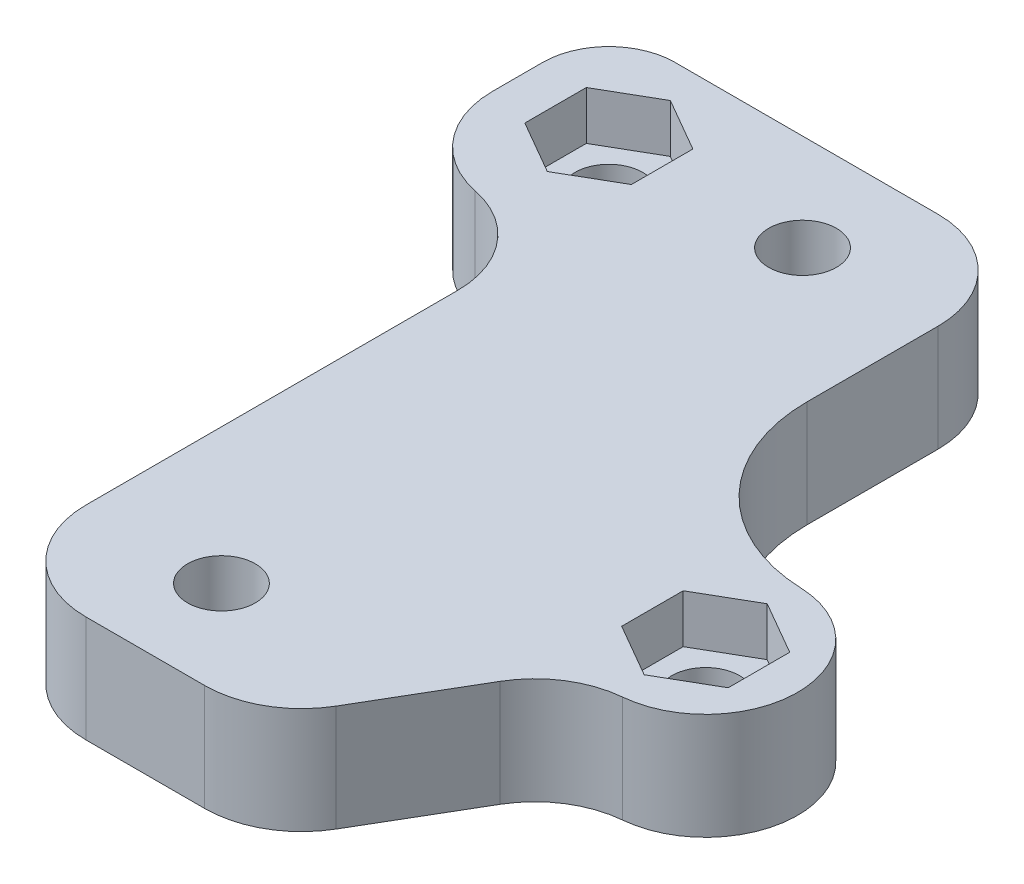
from build123d import *

# Parameters (mm, degrees)
SKETCH2_W           = 35
SKETCH2_H           = 40
SKETCH2_R           = 1.75
BOSS_EXTRUDE2_DEPTH = 5.5
CUT_EXTRUDE1_REACH  = 10.5
CUT_EXTRUDE1_START  = -3
CUT_EXTRUDE2_START  = -3
CUT_EXTRUDE2_DEPTH  = 10
CUT_EXTRUDE3_DEPTH  = 6.5
FILLET3_R           = 5
FILLET4_R           = 8.5


with BuildPart() as part:
    # Sketch2 → Boss-Extrude2 (new body)
    with BuildSketch(Plane(origin=(0, 0, 0), x_dir=(1, 0, 0), z_dir=(0, 1, 0))):
        with Locations((17.5, 20)):
            Rectangle(SKETCH2_W, SKETCH2_H)
        with Locations((5, 35)):
            Circle(SKETCH2_R, mode=Mode.SUBTRACT)
        with Locations((30, 15)):
            Circle(SKETCH2_R, mode=Mode.SUBTRACT)
        with Locations((15, 35)):
            Circle(SKETCH2_R, mode=Mode.SUBTRACT)
        with Locations((15, 5)):
            Circle(SKETCH2_R, mode=Mode.SUBTRACT)
    extrude(amount=BOSS_EXTRUDE2_DEPTH)

    # Sketch3 → Cut-Extrude1 (cut, up to next)
    with BuildSketch(Plane.XZ.offset(CUT_EXTRUDE1_START), mode=Mode.PRIVATE) as cut_extrude1_sk1:
        Polygon((7.75, -36.58771324), (7.75, -33.41228676), (5, -31.824573519), (2.25, -33.41228676), (2.25, -36.58771324), (5, -38.175426481), align=None)
    cut_extrude1_tool1 = extrude(cut_extrude1_sk1.sketch, amount=-CUT_EXTRUDE1_REACH, mode=Mode.PRIVATE) & part.part
    add(cut_extrude1_tool1.solids().sort_by_distance((5, 3, -35))[0], mode=Mode.SUBTRACT)
    # Sketch3 → Cut-Extrude1 (cut, up to next)
    with BuildSketch(Plane.XZ.offset(CUT_EXTRUDE1_START), mode=Mode.PRIVATE) as cut_extrude1_sk2:
        Polygon((30, -11.824573519), (27.25, -13.41228676), (27.25, -16.58771324), (30, -18.175426481), (32.75, -16.58771324), (32.75, -13.41228676), align=None)
    cut_extrude1_tool2 = extrude(cut_extrude1_sk2.sketch, amount=-CUT_EXTRUDE1_REACH, mode=Mode.PRIVATE) & part.part
    add(cut_extrude1_tool2.solids().sort_by_distance((30, 3, -15))[0], mode=Mode.SUBTRACT)

    # Sketch4 → Cut-Extrude2 (cut)
    with BuildSketch(Plane(origin=(0, 5.5, 0), x_dir=(1, 0, 0), z_dir=(0, 1, 0)).offset(CUT_EXTRUDE2_START)):
        Polygon((17.75, 36.58771324), (15, 38.175426481), (12.25, 36.58771324), (12.25, 33.41228676), (15, 31.824573519), (17.75, 33.41228676), align=None)
        Polygon((13.41228676, 7.75), (11.824573519, 5), (13.41228676, 2.25), (16.58771324, 2.25), (18.175426481, 5), (16.58771324, 7.75), align=None)
    extrude(amount=-CUT_EXTRUDE2_DEPTH, mode=Mode.SUBTRACT)

    # Sketch5 → Cut-Extrude3 (cut, through all)
    with BuildSketch(Plane(origin=(0, 5.5, 0), x_dir=(1, 0, 0), z_dir=(0, 1, 0))):
        with BuildLine():
            Line((0, 36.58771324), (0, 40))
            Line((0, 40), (3.41228676, 40))
            ThreePointArc((3.41228676, 40), (0.999435653, 39.000564347), (0, 36.58771324))
        make_face()
        with BuildLine():
            Line((30, 19.75), (22, 19.75))
            Line((22, 19.75), (22, 40))
            Line((22, 40), (35, 40))
            Line((35, 40), (35, 0))
            Line((35, 0), (22, 0))
            Line((22, 0), (28, 10.25))
            Line((28, 10.25), (30, 10.25))
            ThreePointArc((30, 10.25), (34.75, 15), (30, 19.75))
        make_face()
        with BuildLine():
            Line((0, 34), (0, 0))
            Line((0, 0), (8, 0))
            Line((8, 0), (8, 29))
            Line((8, 29), (5, 29))
            ThreePointArc((5, 29), (1.464466094, 30.464466094), (0, 34))
        make_face()
    extrude(amount=-CUT_EXTRUDE3_DEPTH, mode=Mode.SUBTRACT)

    # Fillet3
    fillet3_edges = [part.edges().sort_by_distance(p)[0] for p in [
        (28, 2.75, -10.25),
        (22, 2.75, 0),
        (22, 2.75, -40),
        (8, 2.75, -29),
        (8, 2.75, 0),
    ]]
    fillet(fillet3_edges, radius=FILLET3_R)

    # Fillet4
    fillet4_edges = [part.edges().sort_by_distance(p)[0] for p in [
        (22, 2.75, -19.75),
    ]]
    fillet(fillet4_edges, radius=FILLET4_R)


solid = part.part
